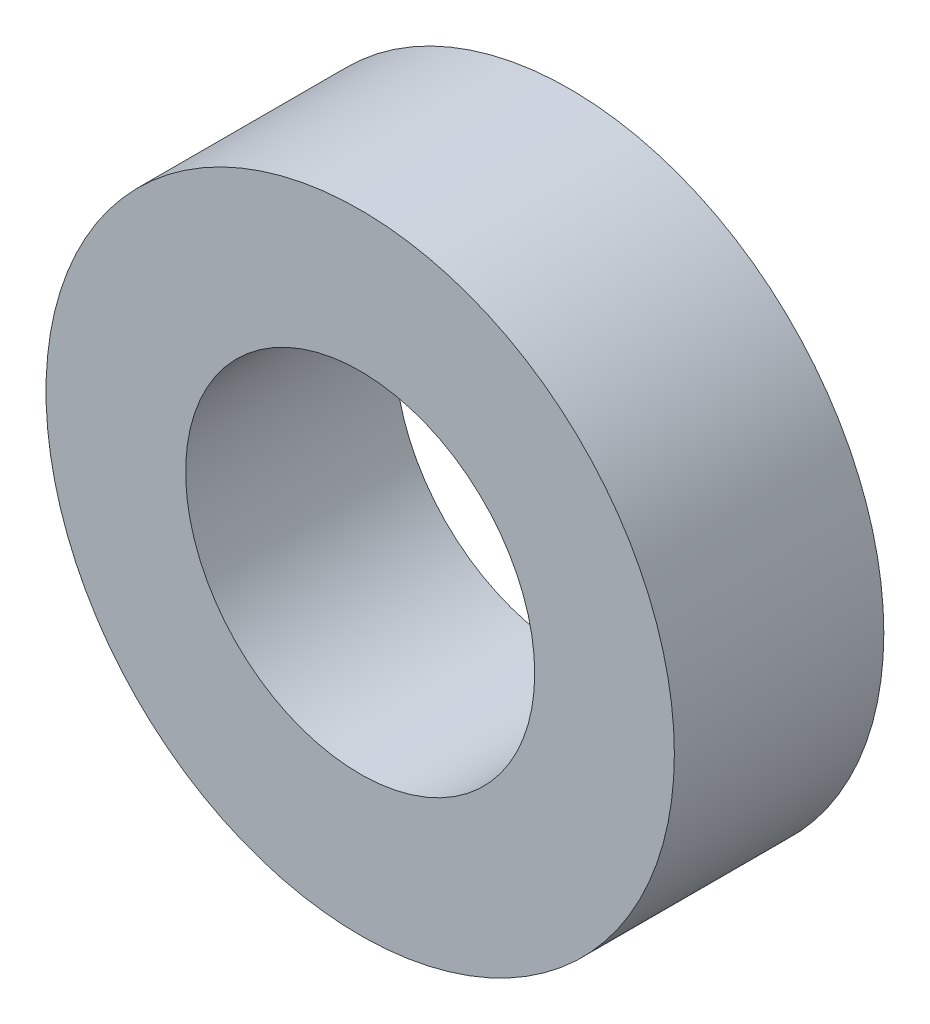
from build123d import *

# Parameters (mm, degrees)
SKETCH1_R           = 4.5
SKETCH1_R_2         = 2.5
BOSS_EXTRUDE1_DEPTH = 3


with BuildPart() as part:
    # Sketch1 → Boss-Extrude1 (new body)
    with BuildSketch(Plane.XY):
        Circle(SKETCH1_R)
        Circle(SKETCH1_R_2, mode=Mode.SUBTRACT)
    extrude(amount=BOSS_EXTRUDE1_DEPTH)


solid = part.part
